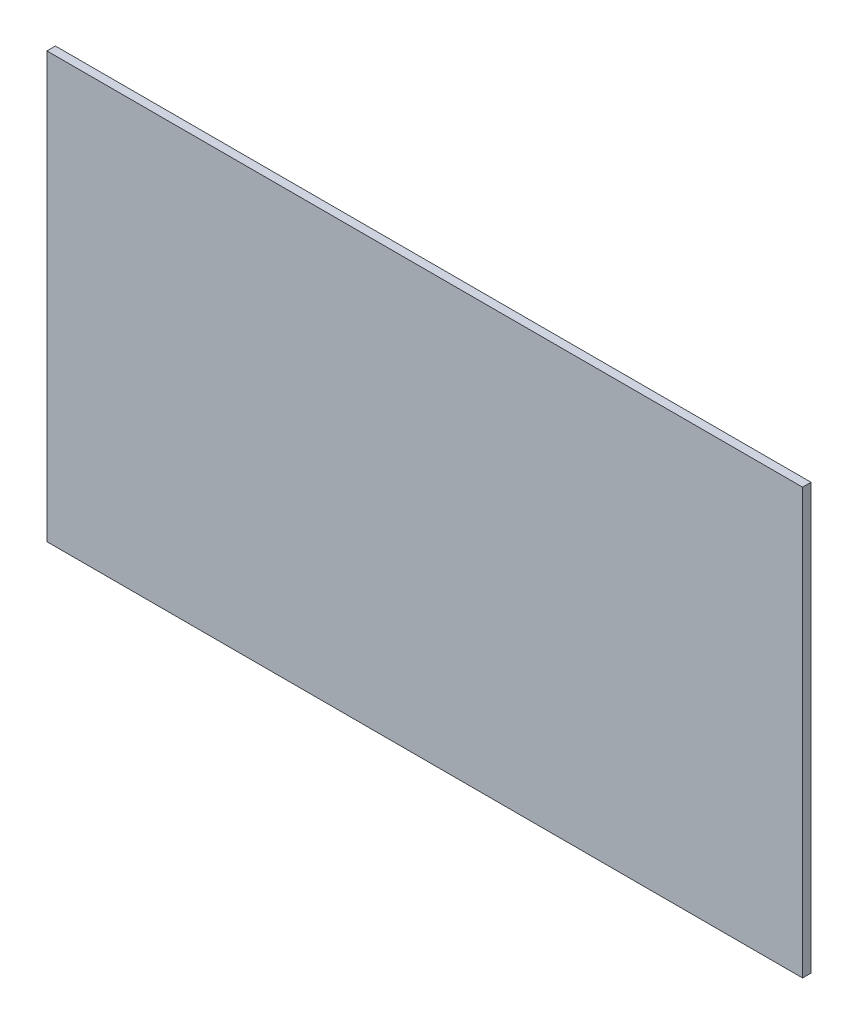
from build123d import *

# Parameters (mm, degrees)
SKETCH1_W           = 1625.6
SKETCH1_H           = 914.4
BOSS_EXTRUDE1_DEPTH = 18.25625


with BuildPart() as part:
    # Sketch1 → Boss-Extrude1 (new body)
    with BuildSketch(Plane.XY):
        with Locations((140.405210467, 21.628935534)):
            Rectangle(SKETCH1_W, SKETCH1_H)
    extrude(amount=BOSS_EXTRUDE1_DEPTH)


solid = part.part
